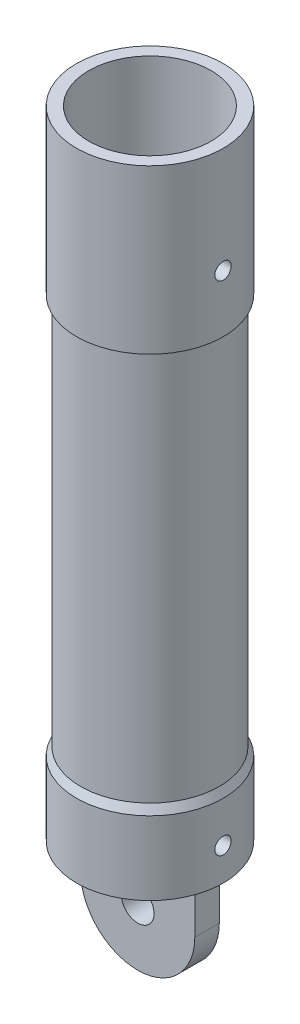
from build123d import *

# Parameters (mm, degrees)
BOSS_EXTRUDE1_DEPTH      = 1.5
BOSS_EXTRUDE1_DEPTH_BACK = 1.5
SKETCH2_R                = 2
SKETCH3_R                = 1
CUT_EXTRUDE1_DEPTH       = 50


with BuildPart() as part:
    # Sketch1 → Revolve1 (revolve)
    with BuildSketch(Plane.XY):
        Polygon((0, 0), (-9, 0), (-9, 9), (-8.5, 10), (-8.5, 58), (-9, 58), (-9, 78), (-7.5, 78), (-7.5, 2), (0, 2), align=None)
    revolve(axis=Axis((0, 78, 0), (0, -1, 0)))

    # Sketch2 → Boss-Extrude1 (add, two sides: drawn at the far end of the back side and taken through both)
    with BuildSketch(Plane.XY.offset(-BOSS_EXTRUDE1_DEPTH_BACK)):
        with BuildLine():
            Line((-7, 0), (7, 0))
            Line((7, 0), (7, -6))
            ThreePointArc((7, -6), (0, -13), (-7, -6))
            Line((-7, -6), (-7, 0))
        make_face()
        with Locations((0, -6)):
            Circle(SKETCH2_R, mode=Mode.SUBTRACT)
    extrude(amount=BOSS_EXTRUDE1_DEPTH + BOSS_EXTRUDE1_DEPTH_BACK)

    # Sketch3 → Cut-Extrude1 (cut)
    with BuildSketch(Plane(origin=(0, 0, 0), x_dir=(0, 0, -1), z_dir=(1, 0, 0))):
        with Locations((0, 65)):
            Circle(SKETCH3_R)
        with Locations((0, 4)):
            Circle(SKETCH3_R)
    extrude(amount=CUT_EXTRUDE1_DEPTH, mode=Mode.SUBTRACT)


solid = part.part
